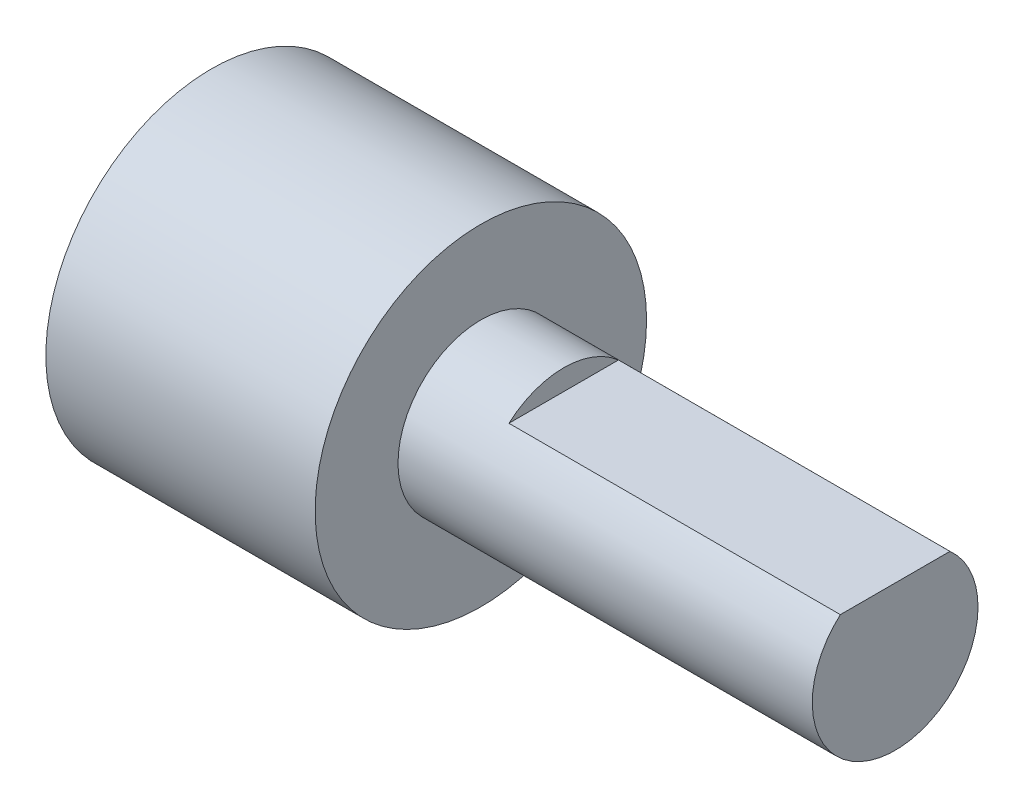
from build123d import *

# Parameters (mm, degrees)
ESQUISSE1_R             = 4
BOSS_EXTRU_1_DEPTH      = 6.5
ESQUISSE2_R             = 2
BOSS_EXTRU_2_DEPTH      = 10
ESQUISSE3_W             = 4
ESQUISSE3_H             = 0.5
ENL_V_MAT_EXTRU_1_DEPTH = 8


with BuildPart() as part:
    # Esquisse1 → Boss.-Extru.1 (new body)
    with BuildSketch(Plane(origin=(0, 0, 0), x_dir=(0, 0, -1), z_dir=(1, 0, 0))):
        Circle(ESQUISSE1_R)
    extrude(amount=BOSS_EXTRU_1_DEPTH)

    # Esquisse2 → Boss.-Extru.2 (add)
    with BuildSketch(Plane(origin=(6.5, 0, 0), x_dir=(0, 0, -1), z_dir=(1, 0, 0))):
        Circle(ESQUISSE2_R)
    extrude(amount=BOSS_EXTRU_2_DEPTH)

    # Esquisse3 → Enlèv. mat.-Extru.1 (cut)
    with BuildSketch(Plane(origin=(16.5, 0, 0), x_dir=(0, 0, -1), z_dir=(1, 0, 0))):
        with Locations((0, 1.75)):
            Rectangle(ESQUISSE3_W, ESQUISSE3_H)
    extrude(amount=-ENL_V_MAT_EXTRU_1_DEPTH, mode=Mode.SUBTRACT)


solid = part.part
